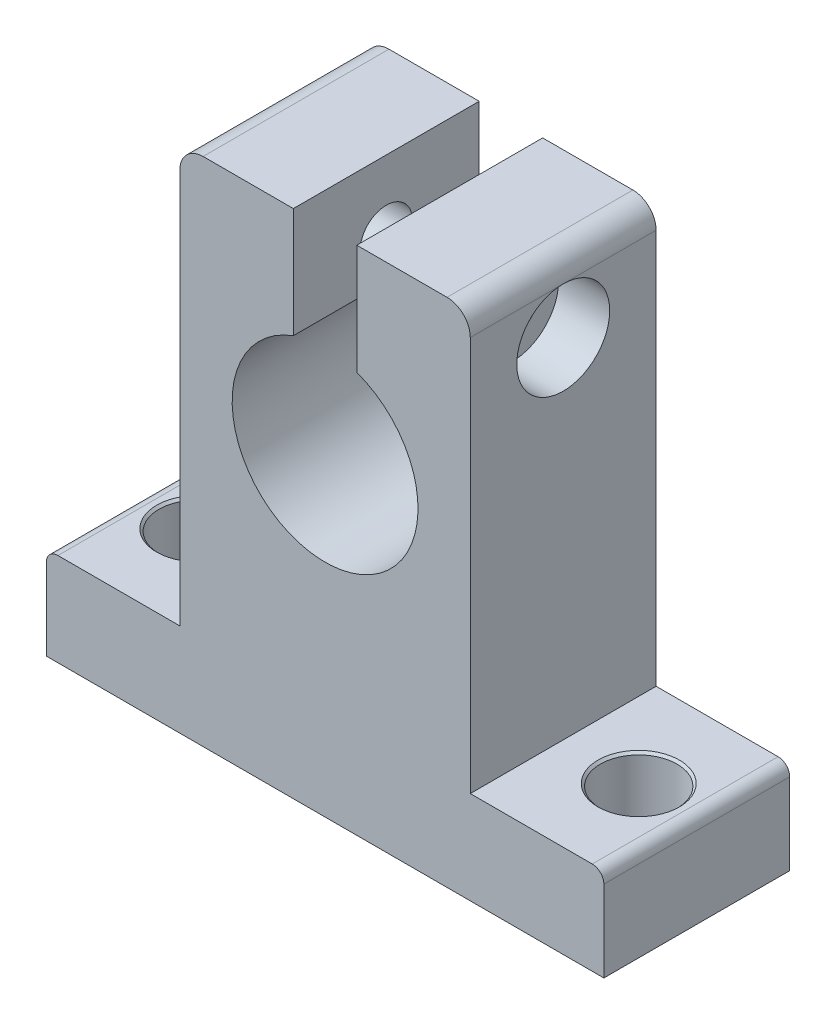
from build123d import *

# Parameters (mm, degrees)
BOSS_EXTRUDE1_DEPTH                                  = 16
CSK_FOR_M5_HEX_SOCKET_COUNTERSUNK_CAP_SC_D           = 6.6
CSK_FOR_M5_HEX_SOCKET_COUNTERSUNK_CAP_SC_CSINK_D     = 7
CSK_FOR_M5_HEX_SOCKET_COUNTERSUNK_CAP_SC_CSINK_ANGLE = 90
CBORE_FOR_M4_HEX_SOCKET_HEAD_CAP_SCREW1_D            = 4.5
CBORE_FOR_M4_HEX_SOCKET_HEAD_CAP_SCREW1_CBORE_D      = 8
CBORE_FOR_M4_HEX_SOCKET_HEAD_CAP_SCREW1_CBORE_DEPTH  = 4.4


with BuildPart() as part:
    # Sketch1 → Boss-Extrude1 (new body)
    with BuildSketch(Plane.XY):
        with BuildLine():
            Line((24, 0), (-24, 0))
            Line((-24, 0), (-24, 7))
            ThreePointArc((-24, 7), (-23.707106781, 7.707106781), (-23, 8))
            Line((-23, 8), (-12.5, 8))
            Line((-12.5, 8), (-12.5, 42))
            ThreePointArc((-12.5, 42), (-11.914213562, 43.414213562), (-10.5, 44))
            Line((-10.5, 44), (-2.731683137, 44))
            Line((-2.731683137, 44), (-2.731683137, 34.519169318))
            ThreePointArc((-2.731683137, 34.519169318), (0, 19), (2.731683137, 34.519169318))
            Line((2.731683137, 34.519169318), (2.731683137, 44))
            Line((2.731683137, 44), (10.5, 44))
            ThreePointArc((10.5, 44), (11.914213562, 43.414213562), (12.5, 42))
            Line((12.5, 42), (12.5, 8))
            Line((12.5, 8), (23, 8))
            ThreePointArc((23, 8), (23.707106781, 7.707106781), (24, 7))
            Line((24, 7), (24, 0))
        make_face()
    extrude(amount=BOSS_EXTRUDE1_DEPTH)

    # CSK for M5 Hex Socket Countersunk Cap Screw1 (through all)
    with Locations(Plane(origin=(-19, 8, 8), x_dir=(0, 0, 1), z_dir=(0, 1, 0))):
        with Locations((0, 0), (0, 38)):
            CounterSinkHole(CSK_FOR_M5_HEX_SOCKET_COUNTERSUNK_CAP_SC_D / 2, CSK_FOR_M5_HEX_SOCKET_COUNTERSUNK_CAP_SC_CSINK_D / 2, counter_sink_angle=CSK_FOR_M5_HEX_SOCKET_COUNTERSUNK_CAP_SC_CSINK_ANGLE)

    # CBORE for M4 Hex Socket Head Cap Screw1 (through all)
    with Locations(Plane(origin=(12.5, 38, 8), x_dir=(0, 0, 1), z_dir=(1, 0, 0))):
        with Locations((0, 0)):
            CounterBoreHole(CBORE_FOR_M4_HEX_SOCKET_HEAD_CAP_SCREW1_D / 2, CBORE_FOR_M4_HEX_SOCKET_HEAD_CAP_SCREW1_CBORE_D / 2, CBORE_FOR_M4_HEX_SOCKET_HEAD_CAP_SCREW1_CBORE_DEPTH)


solid = part.part
